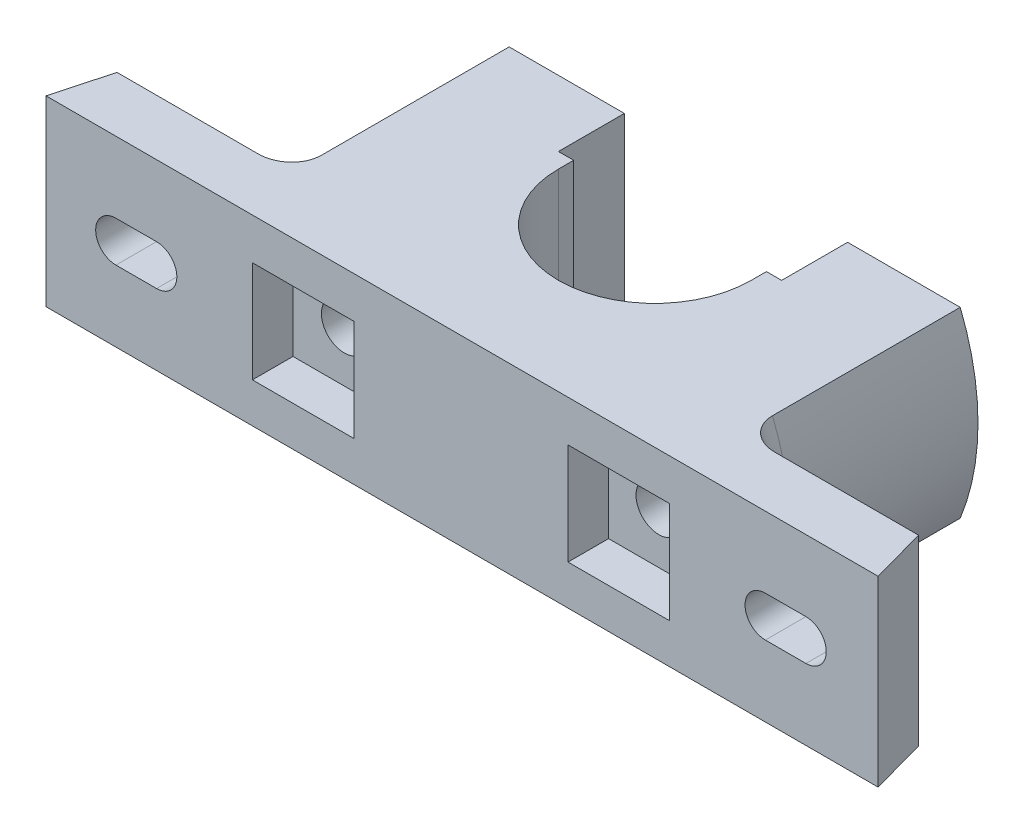
from build123d import *

# Parameters (mm, degrees)
BOSS_EXTRUDE1_DEPTH       = 18
CUT_EXTRUDE2_DEPTH        = 43
FILLET2_R                 = 6
SKETCH4_R                 = 4.5
CUT_EXTRUDE3_DEPTH        = 55.0000001
SKETCH5_W                 = 20
SKETCH5_H                 = 20
CUT_EXTRUDE6_DEPTH        = 7.92
CUT_EXTRUDE7_DEPTH        = 12.0000001
F_6_0MM_DOWEL_HOLE1_D     = 6
F_6_0MM_DOWEL_HOLE1_DEPTH = 6
F_6_0MM_DOWEL_HOLE1_TIP   = 1.802581857
CUT_EXTRUDE8_DEPTH        = 43
FILLET3_R                 = 6


with BuildPart() as part:
    # Sketch1 → Boss-Extrude1 (new body, symmetric)
    with BuildSketch(Plane(origin=(0, 0, 0), x_dir=(1, 0, 0), z_dir=(0, 1, 0))):
        with BuildLine():
            Line((19.211898334, 37.921604348), (19.211898334, 40.921604348))
            Line((19.211898334, 40.921604348), (22.211898334, 40.921604348))
            Line((22.211898334, 40.921604348), (22.211898334, 53.921604348))
            Line((22.211898334, 53.921604348), (50.211898334, 53.921604348))
            Line((50.211898334, 53.921604348), (50.211898334, 10.921604348))
            Line((50.211898334, 10.921604348), (79.211898334, 10.921604348))
            Line((79.211898334, 10.921604348), (82.211898334, -0.078395652))
            Line((82.211898334, -0.078395652), (-81.788101666, -0.078395652))
            Line((-81.788101666, -0.078395652), (-78.788101666, 10.921604348))
            Line((-78.788101666, 10.921604348), (-49.788101666, 10.921604348))
            Line((-49.788101666, 10.921604348), (-49.788101666, 53.921604348))
            Line((-49.788101666, 53.921604348), (-21.788101666, 53.921604348))
            Line((-21.788101666, 53.921604348), (-21.788101666, 40.921604348))
            Line((-21.788101666, 40.921604348), (-18.788101666, 40.921604348))
            Line((-18.788101666, 40.921604348), (-18.788101666, 37.921604348))
            ThreePointArc((-18.788101666, 37.921604348), (0.211898334, 18.921604348), (19.211898334, 37.921604348))
        make_face()
    extrude(amount=BOSS_EXTRUDE1_DEPTH, both=True)

    # Sketch3 → Cut-Extrude2 (cut)
    with BuildSketch(Plane(origin=(0, 0, -53.921604348), x_dir=(-1, 0, 0), z_dir=(0, 0, -1))):
        with BuildLine():
            Line((44.497190923, 18), (49.788101666, 18))
            Line((49.788101666, 18), (49.788101666, -18))
            Line((49.788101666, -18), (44.497190923, -18))
            ThreePointArc((44.497190923, -18), (48, 0), (44.497190923, 18))
        make_face()
    extrude(amount=-CUT_EXTRUDE2_DEPTH, mode=Mode.SUBTRACT)

    # Fillet2
    fillet2_edges = [part.edges().sort_by_distance(p)[0] for p in [
        (-48, 0, -10.921604348),
    ]]
    fillet(fillet2_edges, radius=FILLET2_R)

    # Sketch4 → Cut-Extrude3 (cut, through all)
    with BuildSketch(Plane(origin=(0, 0, -53.921604348), x_dir=(-1, 0, 0), z_dir=(0, 0, -1))):
        with Locations((31, 0)):
            Circle(SKETCH4_R)
    cut_extrude3 = extrude(amount=-CUT_EXTRUDE3_DEPTH, mode=Mode.SUBTRACT)

    # Sketch5 → Cut-Extrude6 (cut, symmetric)
    with BuildSketch(Plane.XY):
        with Locations((-31.09995798, -0.141547283)):
            Rectangle(SKETCH5_W, SKETCH5_H)
    cut_extrude6 = extrude(amount=CUT_EXTRUDE6_DEPTH, both=True, mode=Mode.SUBTRACT)

    # Sketch6 → Cut-Extrude7 (cut, through all)
    with BuildSketch(Plane(origin=(0, 0, -10.921604348), x_dir=(-1, 0, 0), z_dir=(0, 0, -1))):
        with BuildLine():
            Line((60, 4), (68, 4))
            ThreePointArc((68, 4), (72, 0), (68, -4))
            Line((68, -4), (60, -4))
            ThreePointArc((60, -4), (56, 0), (60, 4))
        make_face()
    cut_extrude7 = extrude(amount=-CUT_EXTRUDE7_DEPTH, mode=Mode.SUBTRACT)

    # Ø6.0mm Dowel Hole1
    with Locations(Plane(origin=(0, 0, -18.922785988), x_dir=(-0.999937808, 0, -0.011152544), z_dir=(0.011152544, 0, -0.999937808))):
        with Locations((0, 0)):
            Hole(F_6_0MM_DOWEL_HOLE1_D / 2, depth=F_6_0MM_DOWEL_HOLE1_DEPTH)
            with Locations((0, 0, -(F_6_0MM_DOWEL_HOLE1_DEPTH + F_6_0MM_DOWEL_HOLE1_TIP / 2))):  # 118° drill point
                Cone(0, F_6_0MM_DOWEL_HOLE1_D / 2, F_6_0MM_DOWEL_HOLE1_TIP, mode=Mode.SUBTRACT)

    # Mirror3: Cut-Extrude3, Cut-Extrude6, Cut-Extrude7 across plane
    add(cut_extrude3.mirror(Plane(origin=(0, 0, 0), x_dir=(0, 0, 1), z_dir=(1, 0, 0))), mode=Mode.SUBTRACT)
    add(cut_extrude6.mirror(Plane(origin=(0, 0, 0), x_dir=(0, 0, 1), z_dir=(1, 0, 0))), mode=Mode.SUBTRACT)
    add(cut_extrude7.mirror(Plane(origin=(0, 0, 0), x_dir=(0, 0, 1), z_dir=(1, 0, 0))), mode=Mode.SUBTRACT)

    # Sketch10 → Cut-Extrude8 (cut)
    with BuildSketch(Plane(origin=(0, 0, -53.921604348), x_dir=(-1, 0, 0), z_dir=(0, 0, -1))):
        with BuildLine():
            Line((-50.211898334, -18), (-44.410172286, -18))
            ThreePointArc((-44.410172286, -18), (-47.912981363, 0), (-44.410172286, 18))
            Line((-44.410172286, 18), (-50.211898334, 18))
            Line((-50.211898334, 18), (-50.211898334, -18))
        make_face()
    extrude(amount=-CUT_EXTRUDE8_DEPTH, mode=Mode.SUBTRACT)

    # Fillet3
    fillet3_edges = [part.edges().sort_by_distance(p)[0] for p in [
        (47.912981363, 0, -10.921604348),
    ]]
    fillet(fillet3_edges, radius=FILLET3_R)


solid = part.part
